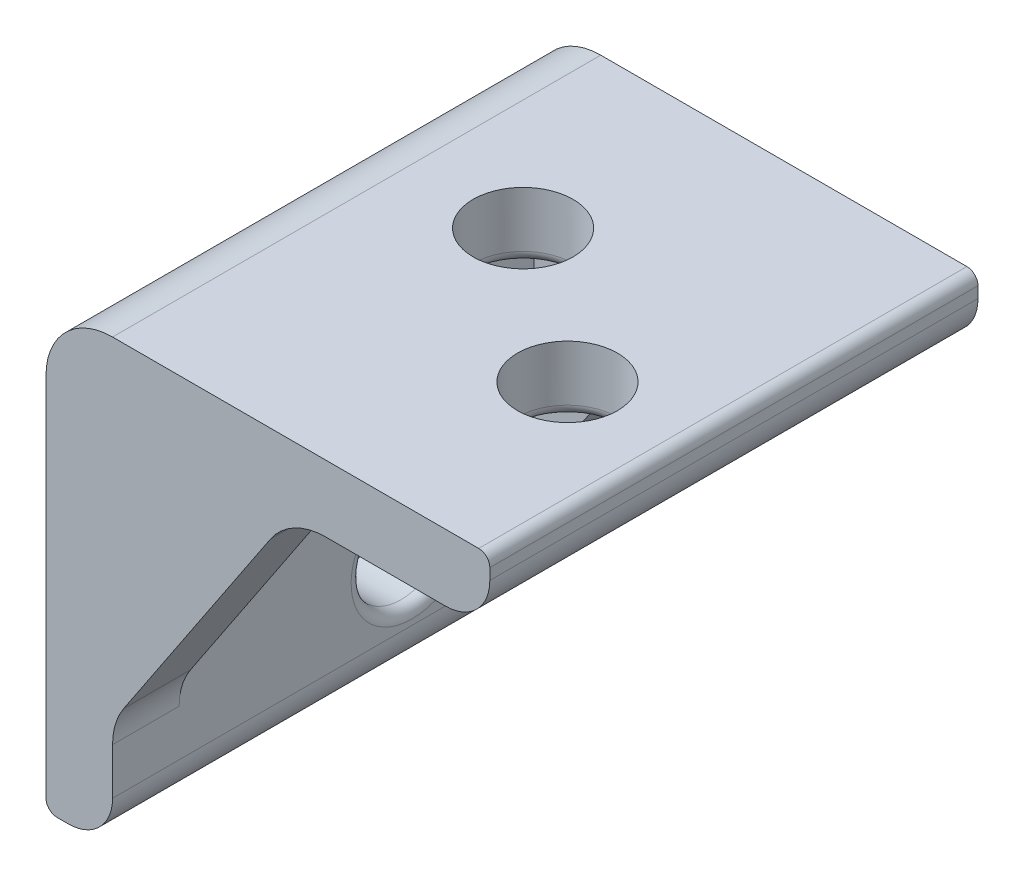
from build123d import *

# Parameters (mm, degrees)
EXTRUDE_1_DEPTH     = 11
SKETCH_4_R          = 2.25
CUT_EXTRUDE_1_DEPTH = 10
SKETCH_2_R          = 2.25
CUT_EXTRUDE_2_DEPTH = 20
FILLET_2_R          = 0.5
RIB_2_REACH         = 36.249
SKETCH_5_WALL_W     = 84.92038026
SKETCH_5_WALL_H     = 3
RIB_3_REACH         = 36.249
SKETCH_6_WALL_W     = 84.92038026
SKETCH_6_WALL_H     = 3
FILLET_3_R          = 3


with BuildPart() as part:
    # 草图1 → 凸台-拉伸1 (new, symmetric)
    with BuildSketch(Plane.XY):
        with BuildLine():
            Line((-17, 0), (-17, -15))
            ThreePointArc((-17, -15), (-17.585786438, -16.414213562), (-19, -17))
            Line((-19, -17), (-19.5, -17))
            ThreePointArc((-19.5, -17), (-19.853553391, -16.853553391), (-20, -16.5))
            Line((-20, -16.5), (-20, 3))
            Line((-20, 3), (-0.5, 3))
            ThreePointArc((-0.5, 3), (-0.146446609, 2.853553391), (0, 2.5))
            Line((0, 2.5), (0, 2))
            ThreePointArc((0, 2), (-0.585786438, 0.585786438), (-2, 0))
            Line((-2, 0), (-17, 0))
        make_face()
    extrude(amount=EXTRUDE_1_DEPTH, both=True)

    # 草图4 → 切除-拉伸1 (cut)
    with BuildSketch(Plane(origin=(0, 0, 0), x_dir=(1, 0, 0), z_dir=(0, 1, 0))):
        with Locations((-5, -2.5)):
            Circle(SKETCH_4_R)
        with Locations((-12, 2.5)):
            Circle(SKETCH_4_R)
    extrude(amount=CUT_EXTRUDE_1_DEPTH, mode=Mode.SUBTRACT)

    # 草图2 → 切除-拉伸2 (cut)
    with BuildSketch(Plane(origin=(-17, 0, 0), x_dir=(0, 0, -1), z_dir=(1, 0, 0))):
        with Locations((2.5, -12)):
            Circle(SKETCH_2_R)
        with Locations((-2.5, -5)):
            Circle(SKETCH_2_R)
    extrude(amount=-CUT_EXTRUDE_2_DEPTH, mode=Mode.SUBTRACT)

    # 圆角2
    fillet_2_edges = [part.edges().sort_by_distance(p)[0] for p in [
        (-7.25, 0, 2.5),
        (-14.25, 0, -2.5),
        (-17, -12, -0.25),
        (-17, -5, 4.75),
    ]]
    fillet(fillet_2_edges, radius=FILLET_2_R)

    # 草图5 wall → 筋2 (add, up to next)
    with BuildSketch(Plane(origin=(-13, -6, -11), x_dir=(-0.554700196225, -0.832050294338, 0), z_dir=(0.832050294338, -0.554700196225, 0)), mode=Mode.PRIVATE) as rib_2_sk1:
        with Locations((0, -1.5)):
            Rectangle(SKETCH_5_WALL_W, SKETCH_5_WALL_H)
    rib_2_tool1 = extrude(rib_2_sk1.sketch, amount=-RIB_2_REACH, mode=Mode.PRIVATE) - part.part
    add(rib_2_tool1.solids().sort_by_distance((-13, -6, -11))[0])

    # 草图6 wall → 筋3 (add, up to next)
    with BuildSketch(Plane(origin=(-13, -6, 11), x_dir=(-0.554700196225, -0.832050294338, 0), z_dir=(-0.832050294338, 0.554700196225, 0)), mode=Mode.PRIVATE) as rib_3_sk1:
        with Locations((0, -1.5)):
            Rectangle(SKETCH_6_WALL_W, SKETCH_6_WALL_H)
    rib_3_tool1 = extrude(rib_3_sk1.sketch, amount=RIB_3_REACH, mode=Mode.PRIVATE) - part.part
    add(rib_3_tool1.solids().sort_by_distance((-13, -6, 11))[0])

    # 圆角3
    fillet_3_edges = [part.edges().sort_by_distance(p)[0] for p in [
        (-20, 3, 0),
        (-17, -12, -9.5),
        (-9, 0, -9.5),
        (-17, -12, 9.5),
        (-9, 0, 9.5),
    ]]
    fillet(fillet_3_edges, radius=FILLET_3_R)


solid = part.part
